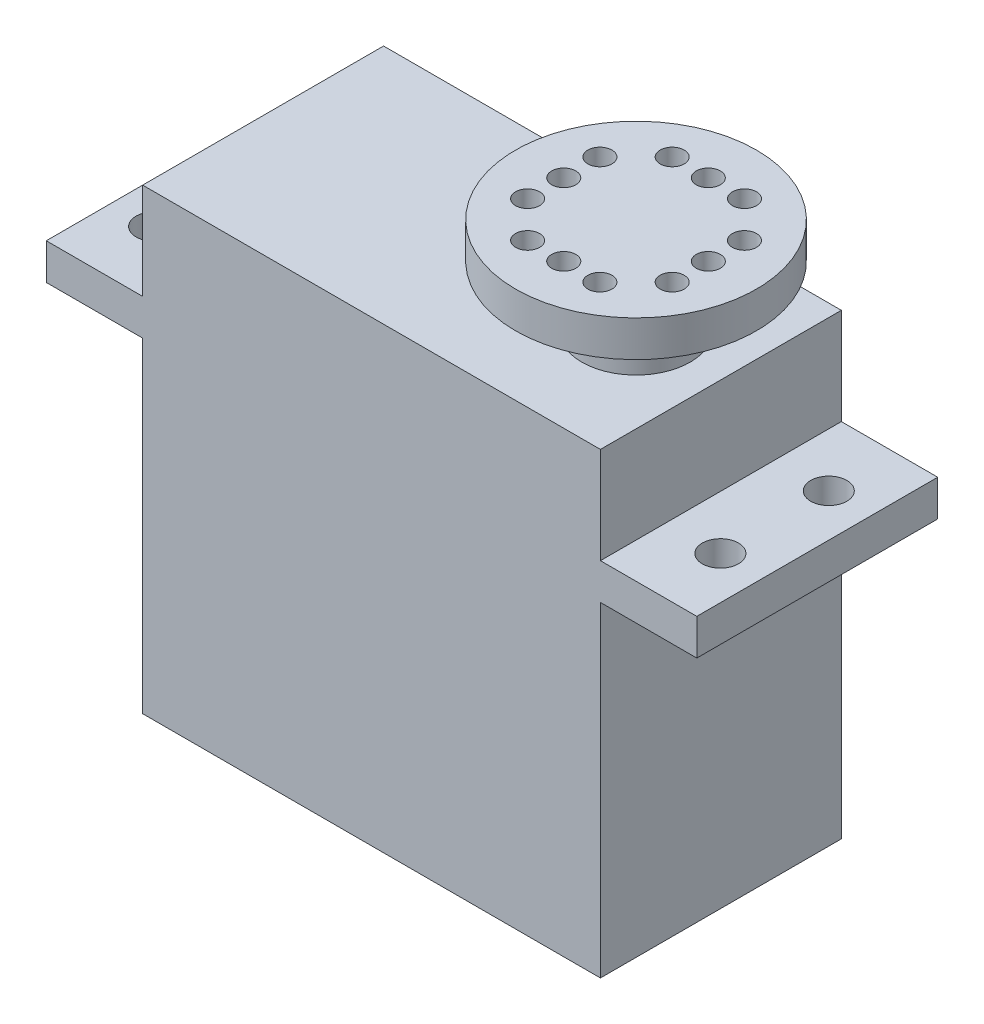
from build123d import *

# Parameters (mm, degrees)
SKETCH1_W           = 38
SKETCH1_H           = 27
SKETCH1_H_2         = 3
SKETCH1_H_3         = 8
SKETCH1_W_2         = 8
BOSS_EXTRUDE1_DEPTH = 20
SKETCH2_R           = 4.5
BOSS_EXTRUDE2_DEPTH = 5
SKETCH3_R           = 10
BOSS_EXTRUDE3_DEPTH = 3
SKETCH4_R           = 1.5
CUT_EXTRUDE1_DEPTH  = 10
SKETCH5_R           = 1
CUT_EXTRUDE2_DEPTH  = 3
CIRPATTERN1_COUNT   = 4


with BuildPart() as part:
    # Sketch1 → Boss-Extrude1 (new body)
    with BuildSketch(Plane.XY):
        with Locations((19, 13.5)):
            Rectangle(SKETCH1_W, SKETCH1_H)
        with Locations((19, 28.5)):
            Rectangle(SKETCH1_W, SKETCH1_H_2)
        with Locations((19, 34)):
            Rectangle(SKETCH1_W, SKETCH1_H_3)
        with Locations((42, 28.5)):
            Rectangle(SKETCH1_W_2, SKETCH1_H_2)
        with Locations((-4, 28.5)):
            Rectangle(SKETCH1_W_2, SKETCH1_H_2)
    extrude(amount=BOSS_EXTRUDE1_DEPTH)

    # Sketch2 → Boss-Extrude2 (add)
    with BuildSketch(Plane(origin=(0, 38, 0), x_dir=(1, 0, 0), z_dir=(0, 1, 0))):
        with Locations((30.956279898, -10)):
            Circle(SKETCH2_R)
    extrude(amount=BOSS_EXTRUDE2_DEPTH)

    # Sketch3 → Boss-Extrude3 (add)
    with BuildSketch(Plane(origin=(0, 43, 0), x_dir=(1, 0, 0), z_dir=(0, 1, 0))):
        with Locations((30.956279898, -10)):
            Circle(SKETCH3_R)
    extrude(amount=BOSS_EXTRUDE3_DEPTH)

    # Sketch4 → Cut-Extrude1 (cut)
    with BuildSketch(Plane(origin=(0, 30, 0), x_dir=(1, 0, 0), z_dir=(0, 1, 0))):
        with Locations((42.456279898, -14.5)):
            Circle(SKETCH4_R)
        with Locations((42.456279898, -5.5)):
            Circle(SKETCH4_R)
        with Locations((-4.543720102, -14.5)):
            Circle(SKETCH4_R)
        with Locations((-4.543720102, -5.5)):
            Circle(SKETCH4_R)
    extrude(amount=-CUT_EXTRUDE1_DEPTH, mode=Mode.SUBTRACT)

    # Sketch5 → Cut-Extrude2 (cut)
    with BuildSketch(Plane(origin=(0, 46, 0), x_dir=(1, 0, 0), z_dir=(0, 1, 0))):
        with Locations((30.956279898, -4)):
            Circle(SKETCH5_R)
        with Locations((27.956279898, -4)):
            Circle(SKETCH5_R)
        with Locations((33.956279898, -4)):
            Circle(SKETCH5_R)
    cut_extrude2 = extrude(amount=-CUT_EXTRUDE2_DEPTH, mode=Mode.SUBTRACT)

    # CirPattern1: Cut-Extrude2 ×4 about axis
    cirpattern1_axis = Axis((30.956279898, 0, 10), (0, 1, 0))
    for i in range(1, CIRPATTERN1_COUNT):
        add(cut_extrude2.rotate(cirpattern1_axis, i * 360 / CIRPATTERN1_COUNT), mode=Mode.SUBTRACT)


solid = part.part
